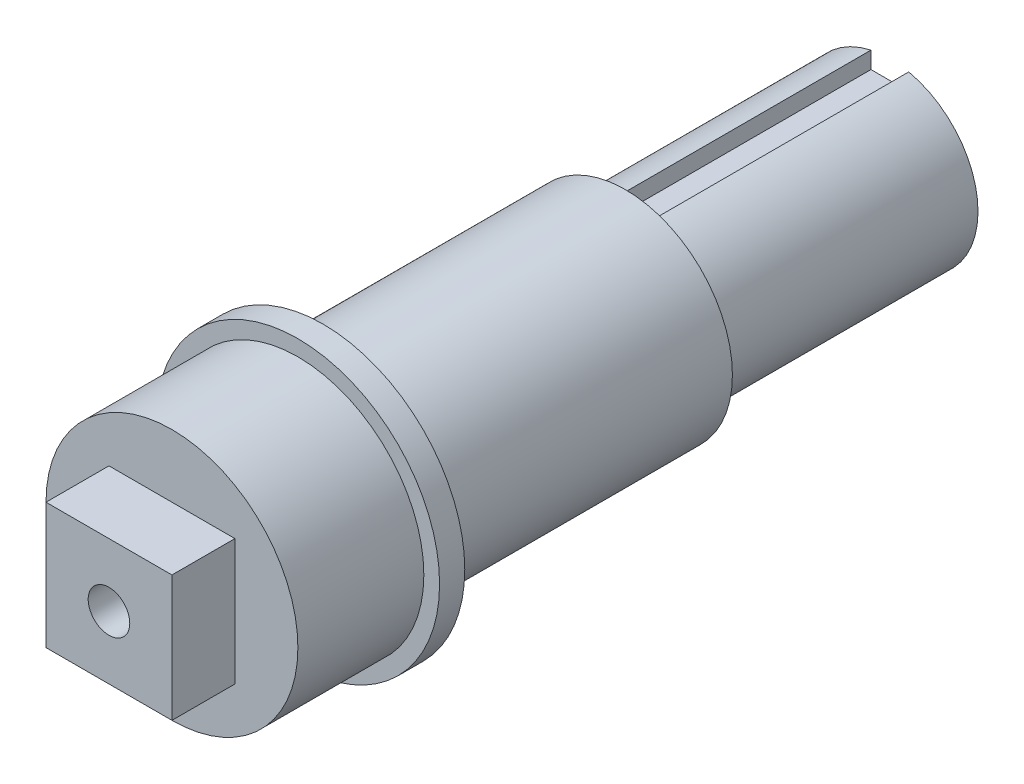
from build123d import *

# Parameters (mm, degrees)
SKETCH1_R                 = 7
BOSS_EXTRUDE1_DEPTH       = 21
SKETCH3_W                 = 3
SKETCH3_H                 = 3
CUT_EXTRUDE1_DEPTH        = 21
SKETCH6_R                 = 8.5
BOSS_EXTRUDE2_DEPTH       = 24
SKETCH7_R                 = 10
BOSS_EXTRUDE3_DEPTH       = 17
FILLET1_R                 = 0.6
SKETCH8_R                 = 11.25
BOSS_EXTRUDE4_DEPTH       = 2
SKETCH10_R                = 11
SKETCH10_W                = 10
SKETCH10_H                = 10
CUT_EXTRUDE2_DEPTH        = 5
M4X0_7_TAPPED_HOLE1_D     = 3.3
M4X0_7_TAPPED_HOLE1_DEPTH = 20
M4X0_7_TAPPED_HOLE1_TIP   = 0.991420021


with BuildPart() as part:
    # Sketch1 → Boss-Extrude1 (new body)
    with BuildSketch(Plane.XY):
        Circle(SKETCH1_R)
    extrude(amount=BOSS_EXTRUDE1_DEPTH)

    # Sketch3 → Cut-Extrude1 (cut)
    with BuildSketch(Plane(origin=(0, 0, 0), x_dir=(-1, 0, 0), z_dir=(0, 0, -1))):
        with Locations((0, 7)):
            Rectangle(SKETCH3_W, SKETCH3_H)
    extrude(amount=-CUT_EXTRUDE1_DEPTH, mode=Mode.SUBTRACT)

    # Sketch6 → Boss-Extrude2 (add)
    with BuildSketch(Plane.XY.offset(21)):
        Circle(SKETCH6_R)
    extrude(amount=BOSS_EXTRUDE2_DEPTH)

    # Sketch7 → Boss-Extrude3 (add)
    with BuildSketch(Plane.XY.offset(45)):
        Circle(SKETCH7_R)
    extrude(amount=BOSS_EXTRUDE3_DEPTH)

    # Fillet1
    fillet1_edges = [part.edges().sort_by_distance(p)[0] for p in [
        (-8.5, 0, 45),
    ]]
    fillet(fillet1_edges, radius=FILLET1_R)

    # Sketch8 → Boss-Extrude4 (add)
    with BuildSketch(Plane(origin=(0, 0, 45), x_dir=(-1, 0, 0), z_dir=(0, 0, -1))):
        Circle(SKETCH8_R)
    extrude(amount=-BOSS_EXTRUDE4_DEPTH)

    # Sketch10 → Cut-Extrude2 (cut)
    with BuildSketch(Plane.XY.offset(57)):
        Circle(SKETCH10_R)
        Rectangle(SKETCH10_W, SKETCH10_H, mode=Mode.SUBTRACT)
    extrude(amount=CUT_EXTRUDE2_DEPTH, mode=Mode.SUBTRACT)

    # M4x0.7 Tapped Hole1
    with Locations(Plane.XY.offset(62)):
        with Locations((0, 0)):
            Hole(M4X0_7_TAPPED_HOLE1_D / 2, depth=M4X0_7_TAPPED_HOLE1_DEPTH)
            with Locations((0, 0, -(M4X0_7_TAPPED_HOLE1_DEPTH + M4X0_7_TAPPED_HOLE1_TIP / 2))):  # 118° drill point
                Cone(0, M4X0_7_TAPPED_HOLE1_D / 2, M4X0_7_TAPPED_HOLE1_TIP, mode=Mode.SUBTRACT)


solid = part.part
